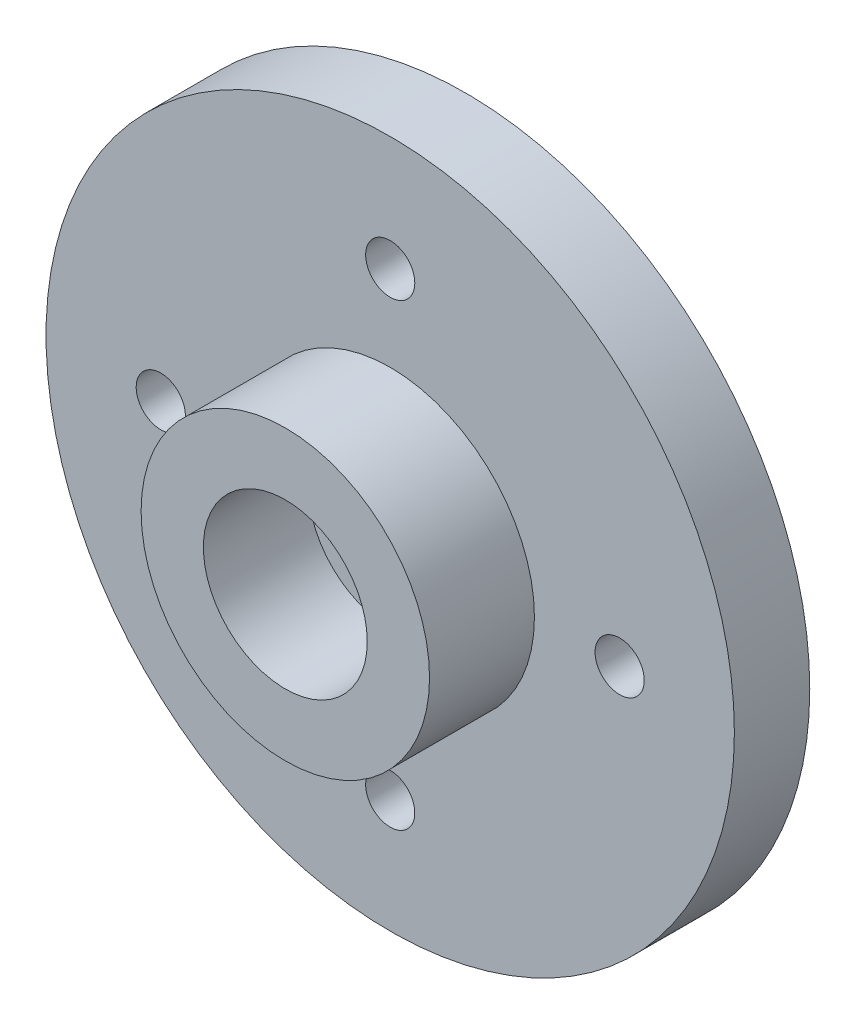
from build123d import *

# Parameters (mm, degrees)
SKETCH1_R           = 10.5
BOSS_EXTRUDE1_DEPTH = 2.3
SKETCH2_R           = 0.75
CUT_EXTRUDE1_DEPTH  = 3.3
SKETCH3_R           = 1.5
CUT_EXTRUDE2_DEPTH  = 2.3
CIRPATTERN1_COUNT   = 4
SKETCH4_R           = 4.4
SKETCH4_R_2         = 2.5
BOSS_EXTRUDE2_DEPTH = 3.2


with BuildPart() as part:
    # Sketch1 → Boss-Extrude1 (new body)
    with BuildSketch(Plane.XY):
        Circle(SKETCH1_R)
    extrude(amount=BOSS_EXTRUDE1_DEPTH)

    # Sketch2 → Cut-Extrude1 (cut, through all)
    with BuildSketch(Plane.XY.offset(2.3)):
        with Locations((0, 7)):
            Circle(SKETCH2_R)
    cut_extrude1 = extrude(amount=-CUT_EXTRUDE1_DEPTH, mode=Mode.SUBTRACT)

    # Sketch3 → Cut-Extrude2 (cut)
    with BuildSketch(Plane.XY.offset(2.3)):
        Circle(SKETCH3_R)
    extrude(amount=-CUT_EXTRUDE2_DEPTH, mode=Mode.SUBTRACT)

    # CirPattern1: Cut-Extrude1 ×4 about axis
    cirpattern1_axis = Axis((0, 0, 0), (0, 0, 1))
    for i in range(1, CIRPATTERN1_COUNT):
        add(cut_extrude1.rotate(cirpattern1_axis, i * 360 / CIRPATTERN1_COUNT), mode=Mode.SUBTRACT)

    # Sketch4 → Boss-Extrude2 (add)
    with BuildSketch(Plane.XY.offset(2.3)):
        Circle(SKETCH4_R)
        Circle(SKETCH4_R_2, mode=Mode.SUBTRACT)
    extrude(amount=BOSS_EXTRUDE2_DEPTH)


solid = part.part
